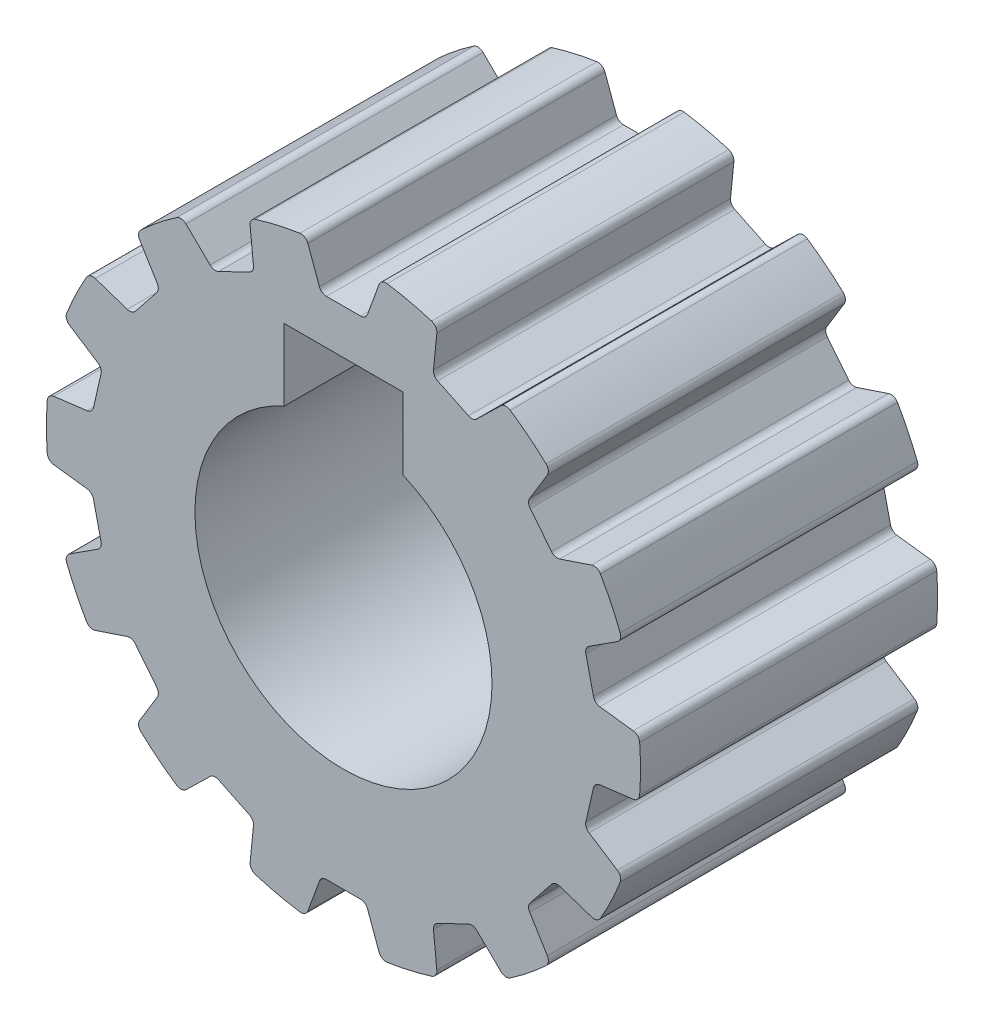
from build123d import *

# Parameters (mm, degrees)
SKETCH1_R           = 10
BOSS_EXTRUDE1_DEPTH = 10
CUT_EXTRUDE1_DEPTH  = 11
CIRPATTERN1_COUNT   = 14
FILLET1_R           = 0.25


with BuildPart() as part:
    # Sketch1 → Boss-Extrude1 (new body)
    with BuildSketch(Plane.XY):
        Circle(SKETCH1_R)
        with BuildLine():
            Line((-2, 7), (2, 7))
            Line((2, 7), (2, 4.582575695))
            ThreePointArc((2, 4.582575695), (0, -5), (-2, 4.582575695))
            Line((-2, 4.582575695), (-2, 7))
        make_face(mode=Mode.SUBTRACT)
    extrude(amount=BOSS_EXTRUDE1_DEPTH)

    # Sketch2 → Cut-Extrude1 (cut, through all)
    with BuildSketch(Plane.XY.offset(10)):
        Polygon((-20.341084154, 62.326061337), (-1.266640021, 9.919456792), (-0.75, 8.5), (0.75, 8.5), (1.266640021, 9.919456792), (20.341084154, 62.326061337), (20.341084154, 173.86594871), (-20.341084154, 173.86594871), align=None)
    cut_extrude1 = extrude(amount=-CUT_EXTRUDE1_DEPTH, mode=Mode.SUBTRACT)

    # CirPattern1: Cut-Extrude1 ×14 about axis
    cirpattern1_axis = Axis((0, 0, 0), (0, 0, 1))
    for i in range(1, CIRPATTERN1_COUNT):
        add(cut_extrude1.rotate(cirpattern1_axis, i * 360 / CIRPATTERN1_COUNT), mode=Mode.SUBTRACT)

    # Fillet1
    fillet1_edges = [part.edges().sort_by_distance(p)[0] for p in [
        (-8.119996553, 2.622623873, 5),
        (-8.453777954, 1.160232004, 5),
        (-9.952609221, 0.972404078, 5),
        (-9.38890138, 3.442169501, 5),
        (-8.453777954, -1.160232004, 5),
        (-8.119996553, -2.622623873, 5),
        (-9.38890138, -3.442169501, 5),
        (-9.952609221, -0.972404078, 5),
        (-7.113184952, -4.713289704, 5),
        (-6.17795025, -5.886036928, 5),
        (-6.965606473, -7.174979196, 5),
        (-8.545080745, -5.194381104, 5),
        (-4.363738433, -7.332822573, 5),
        (-3.012285132, -7.983648182, 5),
        (-3.162687777, -9.486696265, 5),
        (-5.445094229, -8.387547248, 5),
        (-0.75, -8.5, 5),
        (0.75, -8.5, 5),
        (1.266640021, -9.919456792, 5),
        (-1.266640021, -9.919456792, 5),
        (3.012285132, -7.983648182, 5),
        (4.363738433, -7.332822573, 5),
        (5.445094229, -8.387547248, 5),
        (3.162687777, -9.486696265, 5),
        (6.17795025, -5.886036928, 5),
        (7.113184952, -4.713289704, 5),
        (8.545080745, -5.194381104, 5),
        (6.965606473, -7.174979196, 5),
        (8.119996553, -2.622623873, 5),
        (8.453777954, -1.160232004, 5),
        (9.952609221, -0.972404078, 5),
        (9.38890138, -3.442169501, 5),
        (8.453777954, 1.160232004, 5),
        (8.119996553, 2.622623873, 5),
        (9.38890138, 3.442169501, 5),
        (9.952609221, 0.972404078, 5),
        (7.113184952, 4.713289704, 5),
        (6.17795025, 5.886036928, 5),
        (6.965606473, 7.174979196, 5),
        (8.545080745, 5.194381104, 5),
        (4.363738433, 7.332822573, 5),
        (3.012285132, 7.983648182, 5),
        (3.162687777, 9.486696265, 5),
        (5.445094229, 8.387547248, 5),
        (-3.012285132, 7.983648182, 5),
        (-4.363738433, 7.332822573, 5),
        (-5.445094229, 8.387547248, 5),
        (-3.162687777, 9.486696265, 5),
        (0.75, 8.5, 5),
        (-0.75, 8.5, 5),
        (-1.266640021, 9.919456792, 5),
        (1.266640021, 9.919456792, 5),
        (-6.17795025, 5.886036928, 5),
        (-7.113184952, 4.713289704, 5),
        (-8.545080745, 5.194381104, 5),
        (-6.965606473, 7.174979196, 5),
    ]]
    fillet(fillet1_edges, radius=FILLET1_R)


solid = part.part
